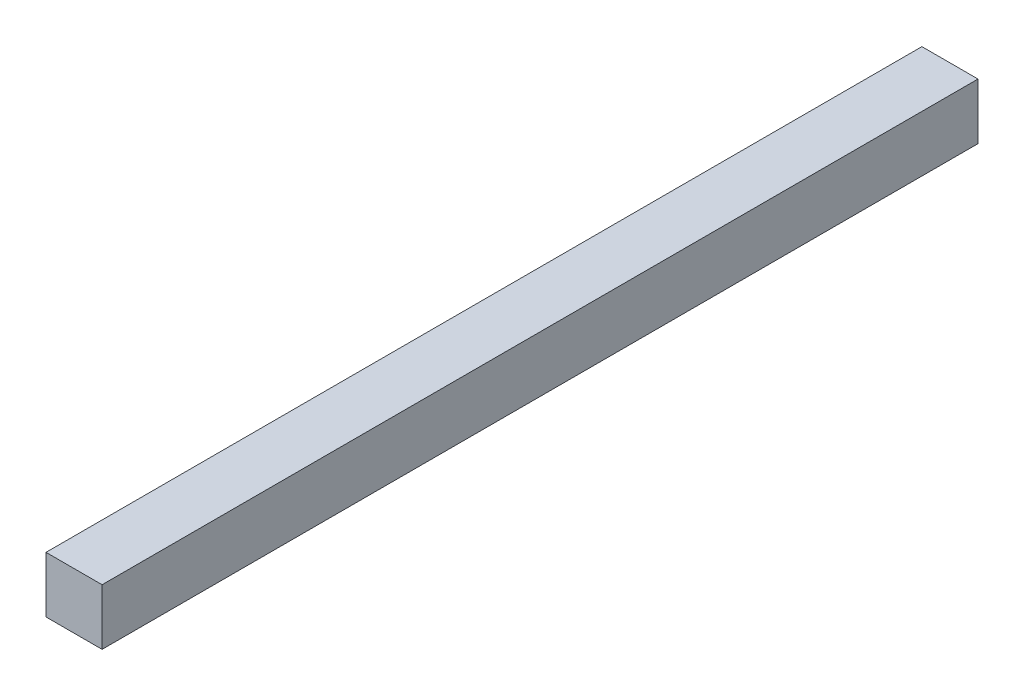
from build123d import *

# Parameters (mm, degrees)
SKETCH1_W           = 30.102258895
SKETCH1_H           = 30.045537442
BOSS_EXTRUDE1_DEPTH = 470


with BuildPart() as part:
    # Sketch1 → Boss-Extrude1 (new body)
    with BuildSketch(Plane.XY.offset(173.036627587)):
        with Locations((-148.556331447, -10.823463775)):
            Rectangle(SKETCH1_W, SKETCH1_H)
    extrude(amount=-BOSS_EXTRUDE1_DEPTH)


solid = part.part
